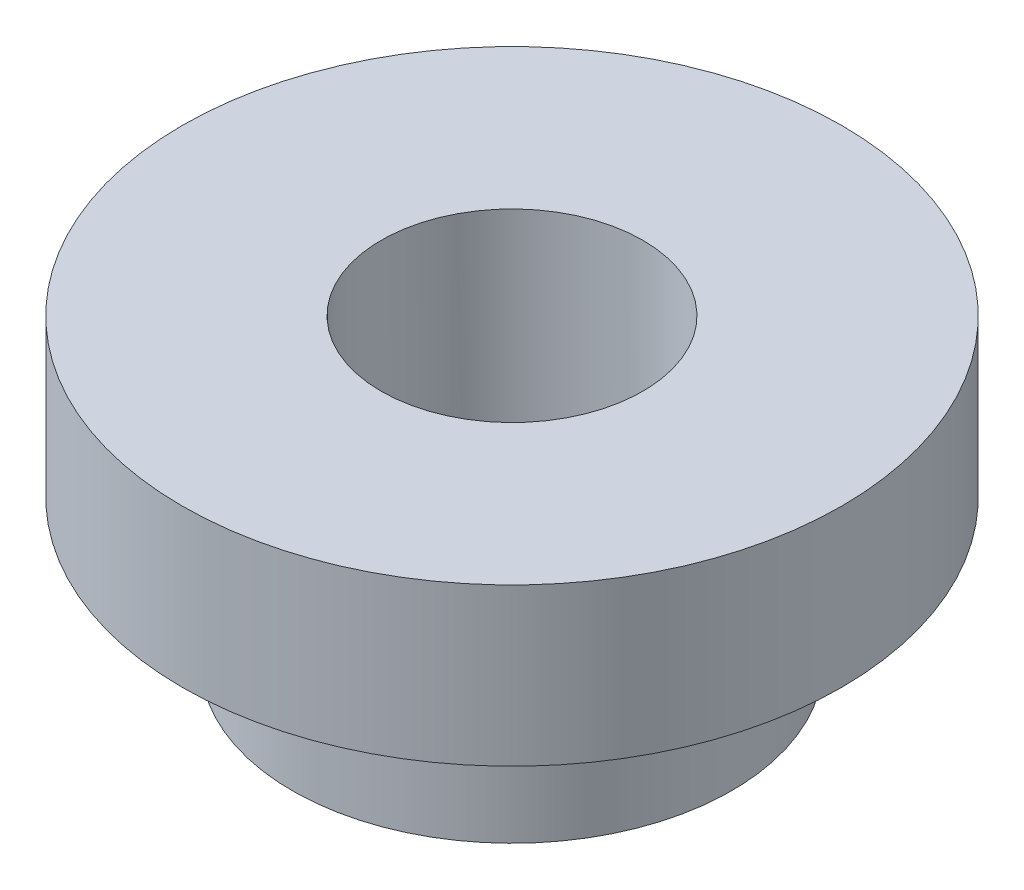
from build123d import *

# Parameters (mm, degrees)
TALADRO_ROSCADO_M31_D     = 2.5
TALADRO_ROSCADO_M31_DEPTH = 10
TALADRO_ROSCADO_M31_TIP   = 0.751075774


with BuildPart() as part:
    # Croquis1 → Revolución1 (revolve)
    with BuildSketch(Plane.XY):
        Polygon((0, 0), (3.15, 0), (3.15, -1.5), (2.1, -1.5), (2.1, -2.88), (0, -2.88), align=None)
    revolve(axis=Axis((0, 0, 0), (0, -1, 0)))

    # Taladro roscado M31
    with Locations(Plane(origin=(0, 0, 0), x_dir=(1, 0, 0), z_dir=(0, 1, 0))):
        with Locations((0, 0)):
            Hole(TALADRO_ROSCADO_M31_D / 2, depth=TALADRO_ROSCADO_M31_DEPTH)
            with Locations((0, 0, -(TALADRO_ROSCADO_M31_DEPTH + TALADRO_ROSCADO_M31_TIP / 2))):  # 118° drill point
                Cone(0, TALADRO_ROSCADO_M31_D / 2, TALADRO_ROSCADO_M31_TIP, mode=Mode.SUBTRACT)


solid = part.part
